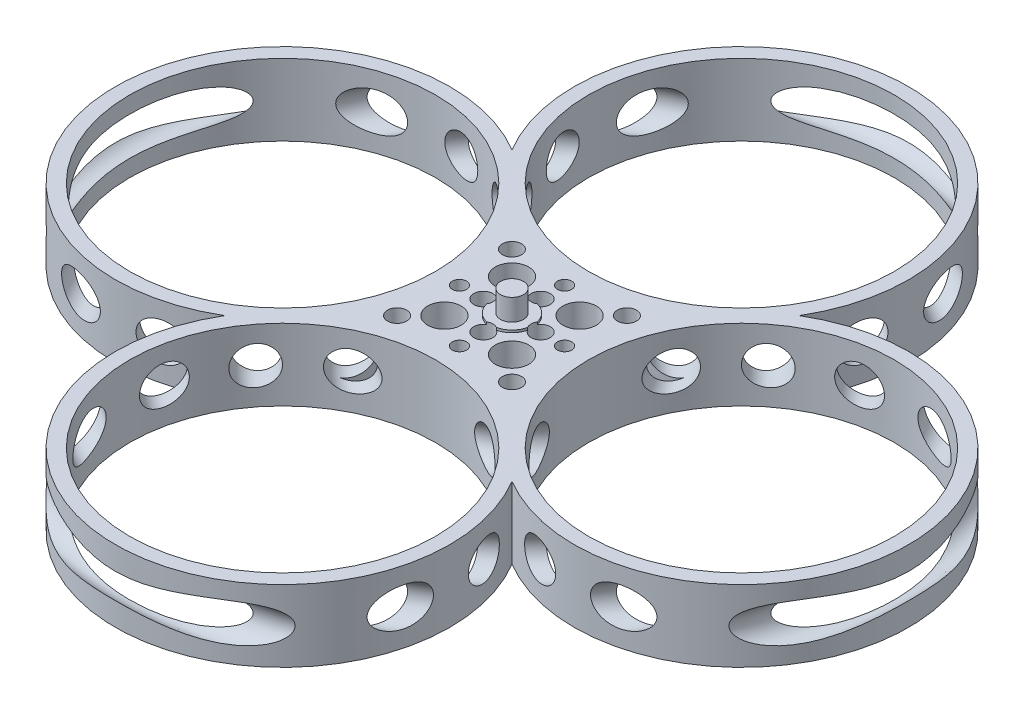
from build123d import *

# Parameters (mm, degrees)
IZIM1_R                     = 35
IZIM1_R_2                   = 32
EKSTR_ZYON_NCE2_DEPTH       = 15
EKSTR_ZYON_NCE2_2_DEPTH     = 15
EKSTR_ZYON_NCE2_3_DEPTH     = 15
EKSTR_ZYON_NCE2_4_DEPTH     = 15
Y_KSEKLIK_EKSTR_ZYON1_START = -5
Y_KSEKLIK_EKSTR_ZYON1_DEPTH = 5
IZIM3_R                     = 2.4
Y_KSEKLIK_EKSTR_ZYON2_DEPTH = 5
IZIM3_3_R                   = 4.4
IZIM3_3_R_2                 = 2.4
Y_KSEKLIK_EKSTR_ZYON3_DEPTH = 0.5
IZIM6_R                     = 3.5
IZIM6_R_2                   = 2
IZIM6_R_3                   = 1.5
KES_EKSTR_ZYON2_DEPTH       = 118.804923496
DAIRESEL_KAPLAMA1_COUNT     = 4
IZIM7_R                     = 3.5
IZIM7_R_2                   = 2.5
Y_KSEKLIK_EKSTR_ZYON4_DEPTH = 6
KES_EKSTR_ZYON3_START       = -3
IZIM7_2_R                   = 2.5
KES_EKSTR_ZYON3_DEPTH       = 3
SKETCH2_R                   = 4


with BuildPart() as part:
    # Çizim1 → Ekstrüzyon-İnce2 (new body)
    with BuildSketch(Plane(origin=(0, 0, 0), x_dir=(1, 0, 0), z_dir=(0, 1, 0))):
        with Locations((0, 48)):
            Circle(IZIM1_R)
        with Locations((0, 48)):
            Circle(IZIM1_R_2, mode=Mode.SUBTRACT)
    extrude(amount=EKSTR_ZYON_NCE2_DEPTH)



with BuildPart() as body_2:
    # Çizim1 → Ekstr_zyon-_nce2 2 (new body)
    with BuildSketch(Plane(origin=(0, 0, 0), x_dir=(1, 0, 0), z_dir=(0, 1, 0))):
        with Locations((48, 0)):
            Circle(IZIM1_R)
        with Locations((48, 0)):
            Circle(IZIM1_R_2, mode=Mode.SUBTRACT)
    extrude(amount=EKSTR_ZYON_NCE2_2_DEPTH)


with BuildPart() as body_3:
    # Çizim1 → Ekstr_zyon-_nce2 3 (new body)
    with BuildSketch(Plane(origin=(0, 0, 0), x_dir=(1, 0, 0), z_dir=(0, 1, 0))):
        with Locations((-48, 0)):
            Circle(IZIM1_R)
        with Locations((-48, 0)):
            Circle(IZIM1_R_2, mode=Mode.SUBTRACT)
    extrude(amount=EKSTR_ZYON_NCE2_3_DEPTH)


with BuildPart() as body_4:
    # Çizim1 → Ekstr_zyon-_nce2 4 (new body)
    with BuildSketch(Plane(origin=(0, 0, 0), x_dir=(1, 0, 0), z_dir=(0, 1, 0))):
        with Locations((0, -48)):
            Circle(IZIM1_R)
        with Locations((0, -48)):
            Circle(IZIM1_R_2, mode=Mode.SUBTRACT)
    extrude(amount=EKSTR_ZYON_NCE2_4_DEPTH)


with BuildPart() as part_1:
    add(part.part)

    add(body_2.part)  # Yükseklik-Ekstrüzyon1 merges body 2

    add(body_3.part)  # Yükseklik-Ekstrüzyon1 merges body 3

    add(body_4.part)  # Yükseklik-Ekstrüzyon1 merges body 4
    # Çizim2 → Yükseklik-Ekstrüzyon1 (add)
    with BuildSketch(Plane(origin=(0, 15, 0), x_dir=(1, 0, 0), z_dir=(0, 1, 0)).offset(Y_KSEKLIK_EKSTR_ZYON1_START)):
        with BuildLine():
            ThreePointArc((-17.958477013, -17.958477013), (-13, 0), (-17.958477013, 17.958477013))
            ThreePointArc((-17.958477013, 17.958477013), (0, 13), (17.958477013, 17.958477013))
            ThreePointArc((17.958477013, 17.958477013), (13, 0), (17.958477013, -17.958477013))
            ThreePointArc((17.958477013, -17.958477013), (0, -13), (-17.958477013, -17.958477013))
        make_face()
    extrude(amount=Y_KSEKLIK_EKSTR_ZYON1_DEPTH)

    # Çizim3 → Yükseklik-Ekstrüzyon2 (add)
    with BuildSketch(Plane(origin=(0, 15, 0), x_dir=(1, 0, 0), z_dir=(0, 1, 0))):
        Circle(IZIM3_R)
    extrude(amount=Y_KSEKLIK_EKSTR_ZYON2_DEPTH)

    # Çizim3<3> → Yükseklik-Ekstrüzyon3 (add)
    with BuildSketch(Plane(origin=(0, 15, 0), x_dir=(1, 0, 0), z_dir=(0, 1, 0))):
        Circle(IZIM3_3_R)
        Circle(IZIM3_3_R_2, mode=Mode.SUBTRACT)
    extrude(amount=Y_KSEKLIK_EKSTR_ZYON3_DEPTH)

    # Çizim6 → Kes-Ekstrüzyon2 (cut, through all)
    with BuildSketch(Plane.XZ.offset(-10)):
        with Locations((7.071067812, 7.071067812)):
            Circle(IZIM6_R)
        with Locations((12.02081528, 12.02081528)):
            Circle(IZIM6_R_2)
        with Locations((0, 6)):
            Circle(IZIM6_R_2)
        with Locations((0, 11)):
            Circle(IZIM6_R_3)
    kes_ekstr_zyon2 = extrude(amount=-KES_EKSTR_ZYON2_DEPTH, mode=Mode.SUBTRACT)

    # Dairesel Kaplama1: Kes-Ekstrüzyon2 ×4 about axis
    dairesel_kaplama1_axis = Axis((0, 20, 0), (0, -1, 0))
    for i in range(1, DAIRESEL_KAPLAMA1_COUNT):
        add(kes_ekstr_zyon2.rotate(dairesel_kaplama1_axis, i * 360 / DAIRESEL_KAPLAMA1_COUNT), mode=Mode.SUBTRACT)

    # Çizim7 → Yükseklik-Ekstrüzyon4 (add)
    with BuildSketch(Plane.XZ.offset(-10)):
        Circle(IZIM7_R)
        Circle(IZIM7_R_2, mode=Mode.SUBTRACT)
    extrude(amount=Y_KSEKLIK_EKSTR_ZYON4_DEPTH)

    # Çizim7<2> → Kes-Ekstrüzyon3 (cut)
    with BuildSketch(Plane.XZ.offset(-10).offset(KES_EKSTR_ZYON3_START)):
        Circle(IZIM7_2_R)
    extrude(amount=KES_EKSTR_ZYON3_DEPTH, mode=Mode.SUBTRACT)

    # Sketch2 → Cut-Revolve1 (revolve, cut)
    with BuildSketch(Plane(origin=(0, 0, 0), x_dir=(0, 0, -1), z_dir=(1, 0, 0))):
        with Locations((-24, 7.5)):
            Circle(SKETCH2_R)
        with Locations((-38, 7.5)):
            Circle(SKETCH2_R)
        with Locations((-52, 7.5)):
            Circle(SKETCH2_R)
        with Locations((-66, 7.5)):
            Circle(SKETCH2_R)
        with Locations((-80, 7.5)):
            Circle(SKETCH2_R)
    revolve(axis=Axis((0, 0, 0), (0, 1, 0)), mode=Mode.SUBTRACT)


solid = part_1.part
